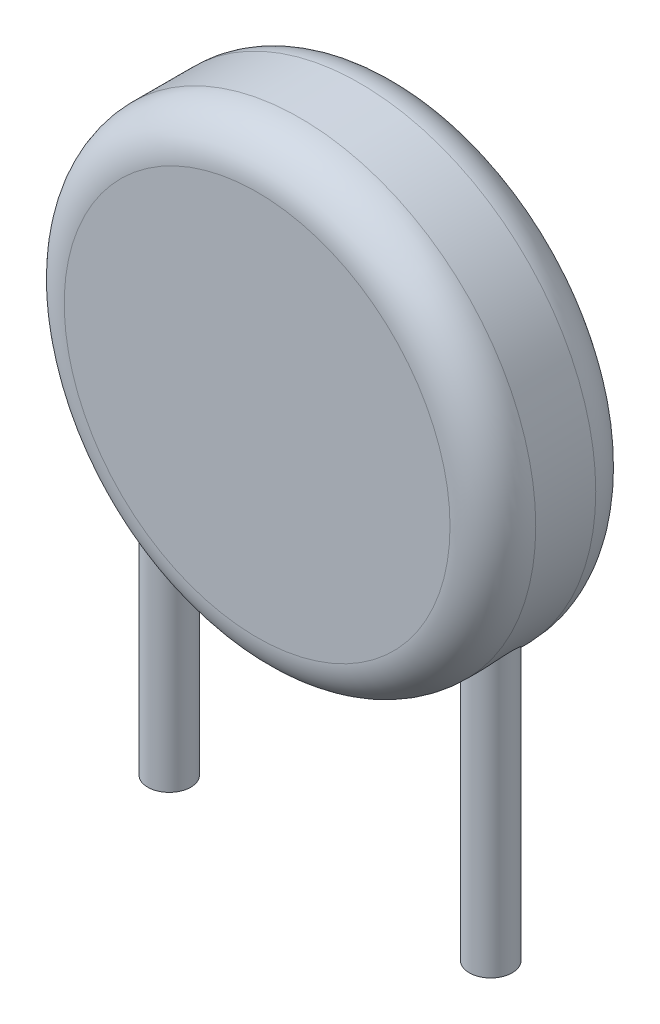
from build123d import *

# Parameters (mm, degrees)
IZIM1_R                     = 5.5
Y_KSEKLIK_EKSTR_ZYON1_DEPTH = 3.4
IZIM2_R                     = 0.5
Y_KSEKLIK_EKSTR_ZYON2_DEPTH = 7
RADYUS1_R                   = 1
IZIM3_W                     = 0.375912343
IZIM3_H                     = 0.125304114
Y_KSEKLIK_EKSTR_ZYON3_DEPTH = 0.01


with BuildPart() as part:
    # Çizim1 → Yükseklik-Ekstrüzyon1 (new body)
    with BuildSketch(Plane.XY):
        Circle(IZIM1_R)
    extrude(amount=Y_KSEKLIK_EKSTR_ZYON1_DEPTH)

    # Çizim2 → Yükseklik-Ekstrüzyon2 (add)
    with BuildSketch(Plane(origin=(0, -10, 0), x_dir=(1, 0, 0), z_dir=(0, 1, 0))):
        with Locations((-3.75, -1.7)):
            Circle(IZIM2_R)
        with Locations((3.75, -1.7)):
            Circle(IZIM2_R)
    extrude(amount=Y_KSEKLIK_EKSTR_ZYON2_DEPTH)

    # Radyus1
    radyus1_edges = [part.edges().sort_by_distance(p)[0] for p in [
        (-5.5, 0, 0),
        (-5.5, 0, 3.4),
    ]]
    fillet(radyus1_edges, radius=RADYUS1_R)

    # Çizim3 → Yükseklik-Ekstrüzyon3 (add)
    with BuildSketch(Plane(origin=(0, 0, 0), x_dir=(-1, 0, 0), z_dir=(0, 0, -1))):
        Polygon((-3.158226168, -0.13427015), (-3.173177227, 0.311235813), (-3.178872869, 0.489046623), (-3.217674427, 0.375667759), (-3.307202793, 0.104946796), (-3.399756968, 0.104946796), (-3.477538073, 0.375667759), (-3.510110023, 0.489046623), (-3.514737732, 0.314795589), (-3.528976836, -0.13427015), (-3.654458939, -0.13427015), (-3.614589448, 0.651728385), (-3.447635955, 0.651728385), (-3.379466245, 0.425326633), (-3.346894295, 0.297708665), (-3.312720445, 0.418029093), (-3.237787161, 0.651728385), (-3.067807858, 0.651728385), (-3.027938367, -0.13427015), align=None)
        with BuildLine():
            add(Edge.make_bspline(
                [(-2.350157022, 0.262288894), (-2.350463326, 0.245132716), (-2.351054873, 0.212000054), (-2.355610557, 0.164073141), (-2.363559598, 0.119838751), (-2.374589881, 0.079235579), (-2.388296997, 0.042265833), (-2.404349202, 0.008656451), (-2.422815496, -0.021539899), (-2.443743315, -0.048291182), (-2.466923373, -0.071486607), (-2.491678299, -0.09187108), (-2.518690554, -0.108659552), (-2.547350771, -0.122361483), (-2.577456497, -0.132877594), (-2.608755752, -0.140039206), (-2.640953248, -0.144970134), (-2.662864588, -0.145429624), (-2.673918647, -0.145661433)],
                knots=[0, 0, 0, 0, 5.1464e-05, 9.9389e-05, 0.000144251, 0.000186134, 0.000225444, 0.000262382, 0.000297702, 0.000331421, 0.000364018, 0.000395903, 0.00042741, 0.000459175, 0.000491036, 0.000522854, 0.0005554, 0.000588537, 0.000588537, 0.000588537, 0.000588537], degree=3))
            add(Edge.make_bspline(
                [(-2.673918647, -0.145661433), (-2.686572313, -0.14537498), (-2.71114563, -0.144818692), (-2.746804946, -0.13991051), (-2.780069698, -0.132000507), (-2.810931276, -0.120776575), (-2.839321481, -0.106234154), (-2.865334539, -0.088540487), (-2.888831199, -0.067465619), (-2.909905441, -0.043303555), (-2.928491847, -0.016035072), (-2.944477085, 0.014214273), (-2.95805852, 0.047360378), (-2.968903123, 0.083405583), (-2.977767024, 0.122210935), (-2.98354494, 0.163959836), (-2.987434993, 0.208581188), (-2.987853219, 0.239319281), (-2.988068876, 0.255169342)],
                knots=[0, 0, 0, 0, 3.7945e-05, 7.369e-05, 0.000107751, 0.000140354, 0.000171956, 0.000203206, 0.000234469, 0.000266382, 0.000299163, 0.000333243, 0.000368841, 0.00040645, 0.000446046, 0.000488133, 0.000532787, 0.000580326, 0.000580326, 0.000580326, 0.000580326], degree=3))
            add(Edge.make_bspline(
                [(-2.988068876, 0.255169342), (-2.987767141, 0.272326226), (-2.987184417, 0.305460252), (-2.98257396, 0.353309022), (-2.974855323, 0.397509114), (-2.963865815, 0.438089441), (-2.949839658, 0.475012472), (-2.933939718, 0.508771592), (-2.915401793, 0.538994539), (-2.894484285, 0.565749354), (-2.871303791, 0.58894833), (-2.846541083, 0.609315808), (-2.819581619, 0.626154448), (-2.790829066, 0.639610062), (-2.760697097, 0.650148573), (-2.729428272, 0.657508017), (-2.697213001, 0.662429635), (-2.675361014, 0.662887871), (-2.664307252, 0.663119668)],
                knots=[0, 0, 0, 0, 5.1464e-05, 9.9389e-05, 0.000144044, 0.000185927, 0.0002253, 0.000262399, 0.000297718, 0.000331437, 0.000364035, 0.000395919, 0.000427426, 0.000459115, 0.000490975, 0.000523008, 0.000555378, 0.000588515, 0.000588515, 0.000588515, 0.000588515], degree=3))
            add(Edge.make_bspline(
                [(-2.664307252, 0.663119668), (-2.651653649, 0.662833123), (-2.627080454, 0.662276654), (-2.591420271, 0.657369744), (-2.558158583, 0.649455252), (-2.527286248, 0.638247083), (-2.498964217, 0.623663583), (-2.472834937, 0.606200284), (-2.44940492, 0.585088436), (-2.428311549, 0.56094667), (-2.409789748, 0.533700376), (-2.393694145, 0.503569058), (-2.380215872, 0.470496312), (-2.369259714, 0.434485984), (-2.360470949, 0.395598316), (-2.354678161, 0.353676793), (-2.350797241, 0.308935615), (-2.350374559, 0.278138762), (-2.350157022, 0.262288894)],
                knots=[0, 0, 0, 0, 3.7945e-05, 7.369e-05, 0.000107751, 0.000140354, 0.000171956, 0.000203106, 0.000234369, 0.000266282, 0.000299063, 0.000332986, 0.000368584, 0.000406023, 0.000445793, 0.000488055, 0.000532887, 0.000580426, 0.000580426, 0.000580426, 0.000580426], degree=3))
        make_face()
        with BuildLine():
            add(Edge.make_bspline(
                [(-2.509634985, 0.255169342), (-2.509711984, 0.266207657), (-2.509861122, 0.287587833), (-2.511727799, 0.318578363), (-2.514443111, 0.347402588), (-2.518507978, 0.374035584), (-2.523833652, 0.398462856), (-2.530216162, 0.420770866), (-2.537552848, 0.440992004), (-2.546396086, 0.458960502), (-2.556223777, 0.475021765), (-2.568009398, 0.488754297), (-2.581272746, 0.500313715), (-2.595786265, 0.510184818), (-2.612076903, 0.51748653), (-2.629830813, 0.522546903), (-2.648995704, 0.525874669), (-2.662275528, 0.526237473), (-2.669112949, 0.526424271)],
                knots=[0, 0, 0, 0, 3.311e-05, 6.4131e-05, 9.3106e-05, 0.00011994, 0.000144903, 0.000168055, 0.000189513, 0.000209333, 0.000228049, 0.000245849, 0.00026338, 0.000280707, 0.00029831, 0.000316671, 0.000335984, 0.00035648, 0.00035648, 0.00035648, 0.00035648], degree=3))
            add(Edge.make_bspline(
                [(-2.669112949, 0.526424271), (-2.675948623, 0.526231952), (-2.689166521, 0.525860071), (-2.708276438, 0.522633349), (-2.725833656, 0.517128047), (-2.741820546, 0.50941201), (-2.75632299, 0.499632711), (-2.769352191, 0.48774786), (-2.781216103, 0.473898032), (-2.791691799, 0.457977665), (-2.80079797, 0.440057914), (-2.808324572, 0.420119978), (-2.814999836, 0.398398879), (-2.820007617, 0.374673118), (-2.82394663, 0.349181218), (-2.826443447, 0.321833024), (-2.828374542, 0.292692947), (-2.828517421, 0.27261587), (-2.828590913, 0.262288894)],
                knots=[0, 0, 0, 0, 2.0497e-05, 3.9633e-05, 5.7928e-05, 7.5521e-05, 9.2701e-05, 0.000110217, 0.000128268, 0.000147273, 0.000167253, 0.000188441, 0.000211132, 0.000235361, 0.000261113, 0.000288475, 0.00031772, 0.000348694, 0.000348694, 0.000348694, 0.000348694], degree=3))
            add(Edge.make_bspline(
                [(-2.828590913, 0.262288894), (-2.828507967, 0.25125113), (-2.828347308, 0.229872021), (-2.826560744, 0.198868029), (-2.823568874, 0.170063397), (-2.819473445, 0.143390165), (-2.814438254, 0.118859702), (-2.808107598, 0.096503803), (-2.800337989, 0.076442294), (-2.791815698, 0.058307431), (-2.781505956, 0.042449031), (-2.769932341, 0.028604249), (-2.756790385, 0.016832882), (-2.742045261, 0.007360713), (-2.725856663, -1.5632e-05), (-2.708217569, -0.005088488), (-2.689173294, -0.00842739), (-2.675950931, -0.008782427), (-2.669112949, -0.008966036)],
                knots=[0, 0, 0, 0, 3.311e-05, 6.4131e-05, 9.3124e-05, 0.000119958, 0.000145057, 0.00016821, 0.000189564, 0.000209544, 0.000228206, 0.000246142, 0.000263539, 0.000280917, 0.00029852, 0.000316711, 0.000335848, 0.000356344, 0.000356344, 0.000356344, 0.000356344], degree=3))
            add(Edge.make_bspline(
                [(-2.669112949, -0.008966036), (-2.66227882, -0.008767596), (-2.649005392, -0.008382181), (-2.629817372, -0.00521751), (-2.612270057, 0.000384863), (-2.596087994, 0.007842572), (-2.581628539, 0.017867512), (-2.56833234, 0.029583239), (-2.556675511, 0.043591322), (-2.5463208, 0.059473554), (-2.537530812, 0.077495022), (-2.529590673, 0.097173835), (-2.523520937, 0.119011866), (-2.518322624, 0.142649607), (-2.51454504, 0.168235962), (-2.511706876, 0.195610665), (-2.509872216, 0.224767644), (-2.509715563, 0.244843165), (-2.509634985, 0.255169342)],
                knots=[0, 0, 0, 0, 2.0497e-05, 3.9809e-05, 5.8104e-05, 7.562e-05, 9.3047e-05, 0.000110695, 0.000128631, 0.000147539, 0.000167438, 0.000188691, 0.00021111, 0.000235339, 0.000261267, 0.000288648, 0.000317892, 0.000348867, 0.000348867, 0.000348867, 0.000348867], degree=3))
        make_face(mode=Mode.SUBTRACT)
        Polygon((-1.910168711, -0.13427015), (-2.10595639, -0.13427015), (-2.34446138, 0.651728385), (-2.176795932, 0.651728385), (-2.045084221, 0.17845617), (-2.002722887, 0.023249937), (-1.959115631, 0.187355609), (-1.829717774, 0.651728385), (-1.672375676, 0.651728385), align=None)
        with Locations((-1.330637183, 0.190381419)):
            Rectangle(IZIM3_W, IZIM3_H)
        Polygon((-0.914855349, -0.13427015), (-0.914855349, -0.008966036), (-0.709812253, -0.008966036), (-0.709812253, 0.497056119), (-0.888335018, 0.401120157), (-0.937637915, 0.526424271), (-0.682757955, 0.651728385), (-0.561725572, 0.651728385), (-0.561725572, -0.008966036), (-0.390856325, -0.008966036), (-0.390856325, -0.13427015), align=None)
        with BuildLine():
            add(Edge.make_bspline(
                [(0.326794511, 0.262288894), (0.326603163, 0.246674583), (0.326229946, 0.216219466), (0.321942724, 0.171823018), (0.315526695, 0.129863353), (0.306292434, 0.090527961), (0.294610308, 0.05387431), (0.280361853, 0.020159921), (0.263863473, -0.010765863), (0.244523664, -0.038457692), (0.222902683, -0.063159059), (0.199075453, -0.084916211), (0.172962243, -0.10350422), (0.144667709, -0.11893333), (0.114164777, -0.130905855), (0.081600235, -0.139373985), (0.046931906, -0.144682806), (0.023106038, -0.145329278), (0.010864393, -0.145661433)],
                knots=[0, 0, 0, 0, 4.6828e-05, 9.1336e-05, 0.000133678, 0.000174088, 0.00021242, 0.000248949, 0.000283752, 0.000317377, 0.000350044, 0.000382047, 0.000413952, 0.000445971, 0.000478494, 0.000511996, 0.000546733, 0.000583442, 0.000583442, 0.000583442, 0.000583442], degree=3))
            add(Edge.make_bspline(
                [(0.010864393, -0.145661433), (0.000228761, -0.145399224), (-0.020774094, -0.144881424), (-0.051570298, -0.140439468), (-0.081205739, -0.133610391), (-0.109386185, -0.1235897), (-0.136151384, -0.110685568), (-0.160794812, -0.094032443), (-0.183822549, -0.07454698), (-0.20475231, -0.051576069), (-0.223389114, -0.025156643), (-0.24030381, 0.004370418), (-0.254550926, 0.037525822), (-0.266892801, 0.07397279), (-0.276674337, 0.114033184), (-0.283471818, 0.157793138), (-0.287545706, 0.205254951), (-0.288065463, 0.238133285), (-0.288334777, 0.255169342)],
                knots=[0, 0, 0, 0, 3.1892e-05, 6.2979e-05, 9.3156e-05, 0.000122992, 0.000152525, 0.000182045, 0.000211969, 0.000242835, 0.000274988, 0.000308788, 0.000344734, 0.000383064, 0.000424118, 0.000468274, 0.000515796, 0.000566899, 0.000566899, 0.000566899, 0.000566899], degree=3))
            add(Edge.make_bspline(
                [(-0.288334777, 0.255169342), (-0.288036263, 0.270779777), (-0.287453024, 0.301279487), (-0.283653778, 0.345730817), (-0.276777149, 0.387626486), (-0.267718597, 0.426964849), (-0.255787896, 0.463592897), (-0.241351991, 0.497266791), (-0.224859785, 0.528175305), (-0.205715516, 0.555910885), (-0.184249437, 0.580650603), (-0.160468153, 0.602443321), (-0.134080709, 0.620764143), (-0.105597732, 0.63623233), (-0.074946661, 0.648338935), (-0.042193608, 0.656851331), (-0.007579127, 0.662110138), (0.016185116, 0.662778656), (0.028307296, 0.663119668)],
                knots=[0, 0, 0, 0, 4.6833e-05, 9.1502e-05, 0.000133697, 0.000174107, 0.000212494, 0.000249093, 0.000283895, 0.000317419, 0.000349969, 0.000381972, 0.00041392, 0.000446095, 0.000479014, 0.000512516, 0.00054743, 0.000583783, 0.000583783, 0.000583783, 0.000583783], degree=3))
            add(Edge.make_bspline(
                [(0.028307296, 0.663119668), (0.038941113, 0.662850252), (0.059940387, 0.662318218), (0.09071917, 0.657986061), (0.120217781, 0.650794368), (0.148404413, 0.640918208), (0.175011754, 0.627883214), (0.199950396, 0.611790692), (0.222514818, 0.591968593), (0.243390059, 0.569180837), (0.262100867, 0.542992666), (0.278708125, 0.513464345), (0.292841187, 0.480388255), (0.305190912, 0.444022456), (0.314919785, 0.403884338), (0.321995273, 0.36003993), (0.325986904, 0.312378096), (0.326518892, 0.279383263), (0.326794511, 0.262288894)],
                knots=[0, 0, 0, 0, 3.1892e-05, 6.2979e-05, 9.3025e-05, 0.000122861, 0.000152393, 0.000181718, 0.000211622, 0.000242237, 0.000274246, 0.000307958, 0.000343669, 0.000382, 0.000423053, 0.000467414, 0.000515113, 0.000566393, 0.000566393, 0.000566393, 0.000566393], degree=3))
        make_face()
        with BuildLine():
            add(Edge.make_bspline(
                [(-0.140248097, 0.255169342), (-0.140241677, 0.25095691), (-0.1402292, 0.242769368), (-0.140317448, 0.230783345), (-0.139996894, 0.219080849), (-0.139337391, 0.211381706), (-0.139002175, 0.207468344)],
                knots=[0, 0, 0, 0, 1.2637e-05, 2.4562e-05, 3.5959e-05, 4.774e-05, 4.774e-05, 4.774e-05, 4.774e-05], degree=3))
            Line((-0.139002175, 0.207468344), (0.157171186, 0.423902723))
            add(Edge.make_bspline(
                [(0.157171186, 0.423902723), (0.153602134, 0.433084548), (0.146795233, 0.450596136), (0.133450257, 0.474101336), (0.118702652, 0.494066302), (0.101934711, 0.510150077), (0.08358334, 0.522636006), (0.063598861, 0.531556316), (0.041982783, 0.536793983), (0.027030508, 0.53747061), (0.019407856, 0.537815554)],
                knots=[0, 0, 0, 0, 2.9519e-05, 5.6298e-05, 8.0825e-05, 0.000103737, 0.000125655, 0.000147089, 0.000169062, 0.000191914, 0.000191914, 0.000191914, 0.000191914], degree=3))
            add(Edge.make_bspline(
                [(0.019407856, 0.537815554), (0.013814472, 0.537618566), (0.002770757, 0.537229627), (-0.013451106, 0.533868738), (-0.029032463, 0.528541504), (-0.043917505, 0.520952308), (-0.058040727, 0.511337749), (-0.071224182, 0.499320573), (-0.08343037, 0.485069942), (-0.094695454, 0.468534702), (-0.104821554, 0.449805478), (-0.113640305, 0.42875539), (-0.121699092, 0.405611469), (-0.12839694, 0.38014438), (-0.133737164, 0.352317599), (-0.13758382, 0.322123409), (-0.139916665, 0.289439547), (-0.140135022, 0.266861336), (-0.140248097, 0.255169342)],
                knots=[0, 0, 0, 0, 1.6765e-05, 3.3101e-05, 4.9481e-05, 6.6038e-05, 8.307e-05, 0.000100586, 0.00011939, 0.000139236, 0.000160501, 0.000183148, 0.000207634, 0.000233969, 0.00026207, 0.00029258, 0.000325234, 0.000360305, 0.000360305, 0.000360305, 0.000360305], degree=3))
        make_face(mode=Mode.SUBTRACT)
        with BuildLine():
            add(Edge.make_bspline(
                [(0.17870783, 0.252677499), (0.178682318, 0.256534989), (0.178630875, 0.264312897), (0.177936837, 0.275930198), (0.177617117, 0.287383597), (0.177512818, 0.294920044), (0.177461909, 0.298598609)],
                knots=[0, 0, 0, 0, 1.1571e-05, 2.333e-05, 3.4905e-05, 4.5942e-05, 4.5942e-05, 4.5942e-05, 4.5942e-05], degree=3))
            Line((0.177461909, 0.298598609), (-0.116753575, 0.082164229))
            add(Edge.make_bspline(
                [(-0.116753575, 0.082164229), (-0.113418809, 0.073926316), (-0.107013475, 0.058103144), (-0.094132723, 0.036950766), (-0.079809637, 0.018724411), (-0.06292562, 0.004338124), (-0.044481095, -0.006759815), (-0.024546066, -0.014751463), (-0.003117095, -0.019440294), (0.011671824, -0.020047169), (0.019229867, -0.020357319)],
                knots=[0, 0, 0, 0, 2.662e-05, 5.1132e-05, 7.4037e-05, 9.5872e-05, 0.00011727, 0.000138357, 0.000160037, 0.000182698, 0.000182698, 0.000182698, 0.000182698], degree=3))
            add(Edge.make_bspline(
                [(0.019229867, -0.020357319), (0.02475934, -0.020134188), (0.035781556, -0.019689409), (0.051978998, -0.016670064), (0.067567531, -0.011358105), (0.082545737, -0.004049123), (0.096847199, 0.005395425), (0.11004067, 0.017100926), (0.1222983, 0.030826414), (0.133474987, 0.046734798), (0.143598358, 0.064829144), (0.152723514, 0.085049395), (0.160466334, 0.107533113), (0.167018124, 0.132222476), (0.17240973, 0.159132307), (0.175971842, 0.188347315), (0.178393623, 0.219767995), (0.178600722, 0.241459158), (0.17870783, 0.252677499)],
                knots=[0, 0, 0, 0, 1.6587e-05, 3.3065e-05, 4.9218e-05, 6.5855e-05, 8.2936e-05, 0.000100467, 0.000118618, 0.000138026, 0.000158668, 0.000180735, 0.000204489, 0.000229919, 0.000257321, 0.000286749, 0.000318161, 0.000351808, 0.000351808, 0.000351808, 0.000351808], degree=3))
        make_face(mode=Mode.SUBTRACT)
        with BuildLine():
            add(Edge.make_bspline(
                [(0.998880215, 0.26869649), (0.998626866, 0.253792818), (0.998131191, 0.224633868), (0.993664615, 0.181948974), (0.986967178, 0.141303987), (0.976918265, 0.102915104), (0.964254059, 0.0668899), (0.948386957, 0.03341559), (0.928992403, 0.002884092), (0.906732887, -0.025113783), (0.881040532, -0.050086698), (0.851901537, -0.071895832), (0.819483601, -0.090827614), (0.783697009, -0.106708091), (0.744379123, -0.119212473), (0.701423794, -0.127952669), (0.654787337, -0.133346414), (0.622449358, -0.133954994), (0.605702959, -0.13427015)],
                knots=[0, 0, 0, 0, 4.4698e-05, 8.7451e-05, 0.000128622, 0.000168166, 0.000206336, 0.000243036, 0.000279035, 0.000314615, 0.00035011, 0.000386206, 0.00042354, 0.000462504, 0.000503426, 0.000547061, 0.000593821, 0.000644046, 0.000644046, 0.000644046, 0.000644046], degree=3))
            Line((0.605702959, -0.13427015), (0.406533493, -0.13427015))
            Line((0.406533493, -0.13427015), (0.406533493, 0.651728385))
            Line((0.406533493, 0.651728385), (0.638808875, 0.651728385))
            add(Edge.make_bspline(
                [(0.638808875, 0.651728385), (0.653357204, 0.651480891), (0.681570959, 0.651000922), (0.722487821, 0.646565853), (0.760670984, 0.639899638), (0.796005935, 0.629843111), (0.828544309, 0.617057519), (0.858496128, 0.601428804), (0.885273818, 0.582189944), (0.909357607, 0.560086864), (0.930833746, 0.535020593), (0.948879503, 0.506386322), (0.964515134, 0.474874793), (0.977013355, 0.440072683), (0.98710813, 0.402112334), (0.993749571, 0.360667092), (0.998164442, 0.315840449), (0.998635925, 0.284786477), (0.998880215, 0.26869649)],
                knots=[0, 0, 0, 0, 4.363e-05, 8.4613e-05, 0.00012333, 0.000159783, 0.00019462, 0.000228061, 0.000260856, 0.000293231, 0.000325935, 0.000359558, 0.000394502, 0.000431272, 0.000470299, 0.000512172, 0.000557051, 0.000605307, 0.000605307, 0.000605307, 0.000605307], degree=3))
        make_face()
        with BuildLine():
            add(Edge.make_bspline(
                [(0.839402251, 0.259085095), (0.839237493, 0.269350981), (0.838916298, 0.289364158), (0.83723997, 0.318544473), (0.8340139, 0.345989649), (0.82961831, 0.37168364), (0.82390997, 0.395714273), (0.816065096, 0.417749491), (0.806584562, 0.437940391), (0.795373761, 0.456257596), (0.78214516, 0.472598311), (0.766794652, 0.486842348), (0.749421981, 0.498982779), (0.729928049, 0.509070473), (0.708138026, 0.516888184), (0.684018974, 0.522512055), (0.657417269, 0.525926528), (0.638879007, 0.526253508), (0.62919748, 0.526424271)],
                knots=[0, 0, 0, 0, 3.08e-05, 6.0045e-05, 8.7642e-05, 0.000113655, 0.000138218, 0.000161637, 0.000183691, 0.00020503, 0.000225906, 0.000246561, 0.000267645, 0.000289299, 0.000312215, 0.000336909, 0.000363468, 0.0003925, 0.0003925, 0.0003925, 0.0003925], degree=3))
            Line((0.62919748, 0.526424271), (0.554620173, 0.526424271))
            Line((0.554620173, 0.526424271), (0.554620173, -0.008966036))
            Line((0.554620173, -0.008966036), (0.619052118, -0.008966036))
            add(Edge.make_bspline(
                [(0.619052118, -0.008966036), (0.62778329, -0.00876156), (0.64476616, -0.008363838), (0.669421748, -0.005269885), (0.692538372, -0.000402903), (0.713998477, 0.006780367), (0.73387194, 0.015813115), (0.752089196, 0.027009729), (0.768689803, 0.040175187), (0.783594042, 0.055514744), (0.796972005, 0.072922652), (0.808205253, 0.092861948), (0.818151335, 0.114834348), (0.825822598, 0.139318709), (0.832105086, 0.16595087), (0.836187638, 0.195027967), (0.838948842, 0.226281607), (0.83924799, 0.247924531), (0.839402251, 0.259085095)],
                knots=[0, 0, 0, 0, 2.6186e-05, 5.0934e-05, 7.4429e-05, 9.6943e-05, 0.000118686, 0.00013978, 0.000160933, 0.000182079, 0.000203794, 0.0002266, 0.000250581, 0.000276023, 0.000303439, 0.000332587, 0.000364027, 0.000397501, 0.000397501, 0.000397501, 0.000397501], degree=3))
        make_face(mode=Mode.SUBTRACT)
        Polygon((1.488883378, -0.13427015), (1.357705633, 0.078426465), (1.216026549, -0.13427015), (1.038749706, -0.13427015), (1.264261514, 0.175786338), (1.055836631, 0.480859139), (1.234181407, 0.480859139), (1.363401275, 0.275816042), (1.494934997, 0.480859139), (1.659574636, 0.480859139), (1.452217685, 0.17685427), (1.670965919, -0.13427015), align=None)
        Polygon((2.160969082, -0.13427015), (2.029791337, 0.078426465), (1.888112253, -0.13427015), (1.71083541, -0.13427015), (1.936347218, 0.175786338), (1.727922335, 0.480859139), (1.906267111, 0.480859139), (2.035486979, 0.275816042), (2.167020701, 0.480859139), (2.33166034, 0.480859139), (2.124303389, 0.17685427), (2.343051623, -0.13427015), align=None)
        Polygon((2.833054786, -0.13427015), (2.701877041, 0.078426465), (2.560197957, -0.13427015), (2.382921114, -0.13427015), (2.608432922, 0.175786338), (2.400008038, 0.480859139), (2.578352815, 0.480859139), (2.707572683, 0.275816042), (2.839106405, 0.480859139), (3.003746044, 0.480859139), (2.796389093, 0.17685427), (3.015137327, -0.13427015), align=None)
        Polygon((3.504962501, -0.13427015), (3.265745555, 0.245735935), (3.265745555, -0.13427015), (3.117658875, -0.13427015), (3.117658875, 0.651728385), (3.265745555, 0.651728385), (3.265745555, 0.286851348), (3.508878255, 0.651728385), (3.687223031, 0.651728385), (3.412408326, 0.274214143), (3.695944482, -0.13427015), align=None)
    extrude(amount=Y_KSEKLIK_EKSTR_ZYON3_DEPTH)


solid = part.part
